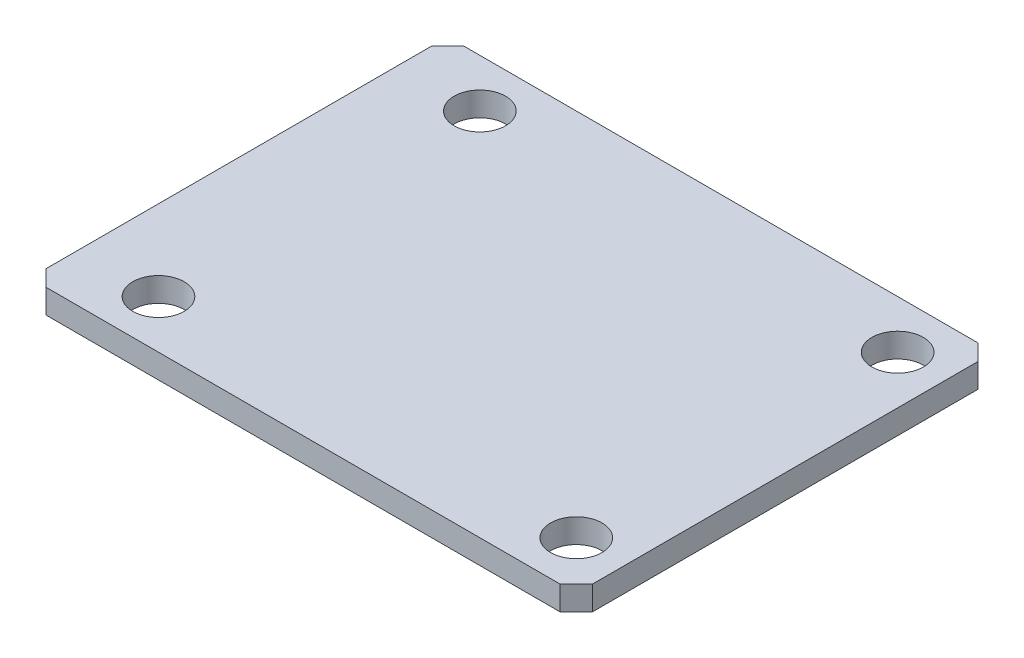
from build123d import *

# Parameters (mm, degrees)
EXTRUDE_1_DEPTH     = 1.5
SKETCH_2_R          = 1.6
CUT_EXTRUDE_1_DEPTH = 1.5


with BuildPart() as part:
    # 草图1 → 凸台-拉伸1 (new body)
    with BuildSketch(Plane(origin=(0, 0, 0), x_dir=(1, 0, 0), z_dir=(0, 1, 0))):
        Polygon((-17, 12), (-16, 13), (16, 13), (17, 12), (17, -12), (16, -13), (-16, -13), (-17, -12), align=None)
    extrude(amount=EXTRUDE_1_DEPTH)

    # 草图2 → 切除-拉伸1 (cut)
    with BuildSketch(Plane(origin=(0, 1.5, 0), x_dir=(1, 0, 0), z_dir=(0, 1, 0))):
        with Locations((14, 10)):
            Circle(SKETCH_2_R)
        with Locations((14, -10)):
            Circle(SKETCH_2_R)
        with Locations((-12, 10)):
            Circle(SKETCH_2_R)
        with Locations((-12, -10)):
            Circle(SKETCH_2_R)
    extrude(amount=-CUT_EXTRUDE_1_DEPTH, mode=Mode.SUBTRACT)


solid = part.part
